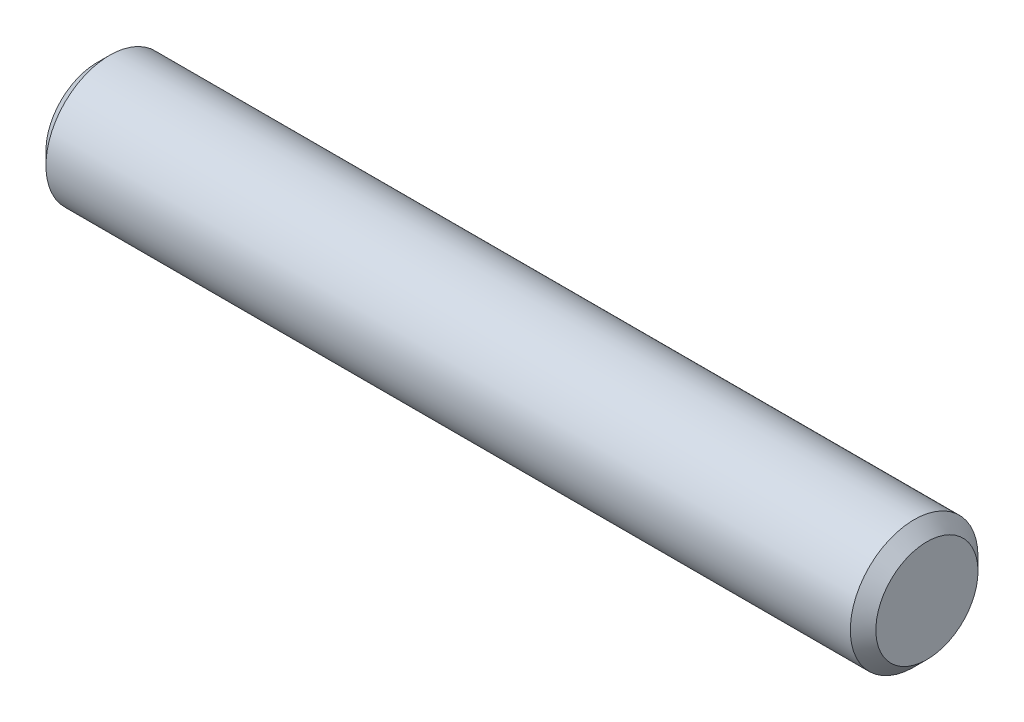
from build123d import *

# Parameters (mm, degrees)
SKETCH2_R           = 3.175
EXTRUDE1_DEPTH      = 20.6375
EXTRUDE1_DEPTH_BACK = 20.6375
CHAMFER1_SIZE       = 0.635


with BuildPart() as part:
    # Sketch2 → Extrude1 (new body, two sides)
    with BuildSketch(Plane(origin=(0, 0, 0), x_dir=(0, 0, -1), z_dir=(1, 0, 0))) as extrude1_sk:
        Circle(SKETCH2_R)
    extrude(amount=EXTRUDE1_DEPTH)
    extrude(extrude1_sk.sketch, amount=-EXTRUDE1_DEPTH_BACK)

    # Chamfer1
    chamfer1_edges = [part.edges().sort_by_distance(p)[0] for p in [
        (-20.6375, 0, 3.175),
        (20.6375, 0, 3.175),
    ]]
    chamfer(chamfer1_edges, length=CHAMFER1_SIZE)


solid = part.part
